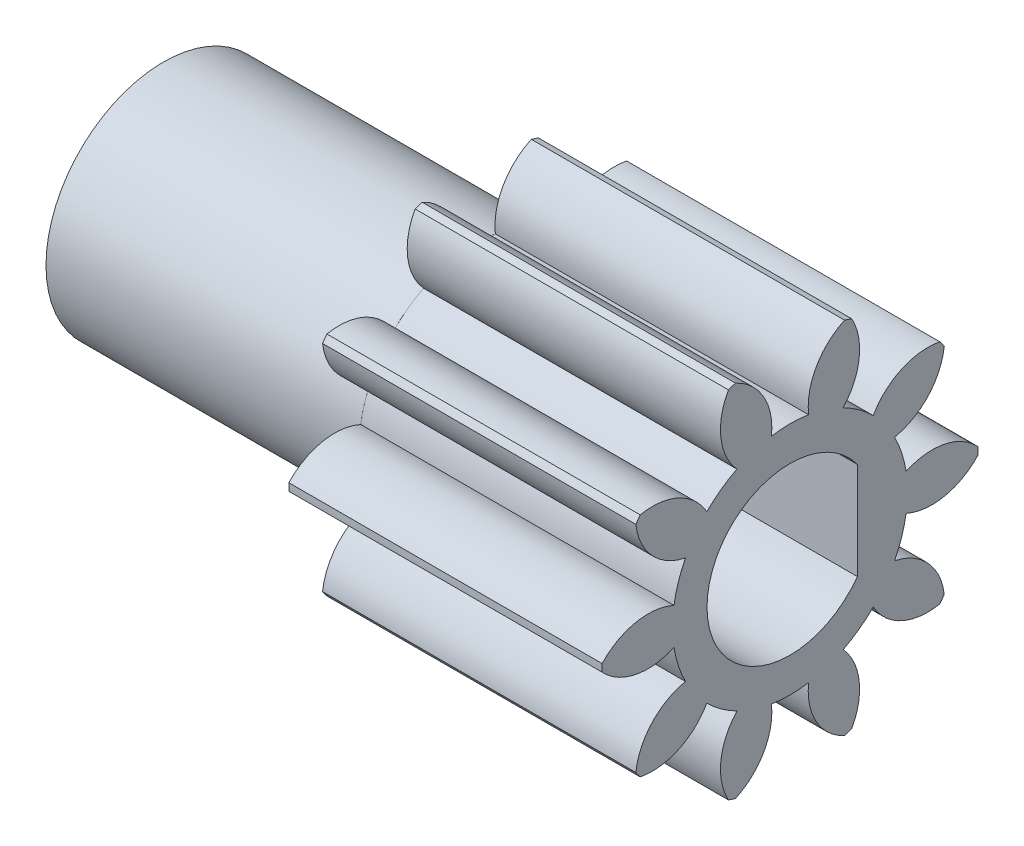
from build123d import *

# Parameters (mm, degrees)
BASPROSKE_W                  = 10
BASPROSKE_H                  = 6
TOOTHCUT_DEPTH               = 14.114877049
TEETHCUTS_COUNT              = 10
TEETHCUTS_ANGLE              = 324
BORSKE_R                     = 0.4
BORE_DEPTH                   = 50.0000508
CROQUIS1_R                   = 3.75
SALIENTE_EXTRUIR1_DEPTH      = 10
TALADRO_DE_MARGEN_PARA_M51_D = 5.3
SALIENTE_EXTRUIR2_DEPTH      = 10


with BuildPart() as part:
    # BasProSke → Base-Revolve (revolve)
    with BuildSketch(Plane(origin=(0, 0, 0), x_dir=(1, 0, 0), z_dir=(0, 1, 0)), mode=Mode.PRIVATE) as base_revolve_sk:
        with Locations((5, 3)):
            Rectangle(BASPROSKE_W, BASPROSKE_H)
    revolve(base_revolve_sk.sketch.rotate(Axis((-10, 0, 0), (1, 0, 0)), 180), axis=Axis((-10, 0, 0), (1, 0, 0)))

    # TooCutSke → ToothCut (cut, through all)
    with BuildSketch(Plane(origin=(0, 0, 0), x_dir=(0, 0, -1), z_dir=(1, 0, 0))):
        with BuildLine():
            ThreePointArc((0.59278292, 3.701838653), (0, 3.749), (-0.59278292, 3.701838653))
            ThreePointArc((-0.59278292, 3.701838653), (-0.846593509, 4.924114224), (-1.775771316, 5.757784417))
            ThreePointArc((-1.775771316, 5.757784417), (0, 6.0254), (1.775771316, 5.757784417))
            ThreePointArc((1.775771316, 5.757784417), (0.846593509, 4.924114224), (0.59278292, 3.701838653))
        make_face()
    toothcut = extrude(amount=TOOTHCUT_DEPTH, mode=Mode.SUBTRACT)

    # TeethCuts: ToothCut ×10 about axis
    teethcuts_axis = Axis((-10, 0, 0), (1, 0, 0))
    for i in range(1, TEETHCUTS_COUNT):
        add(toothcut.rotate(teethcuts_axis, i * TEETHCUTS_ANGLE / (TEETHCUTS_COUNT - 1)), mode=Mode.SUBTRACT)

    # BorSke → Bore (cut, symmetric)
    with BuildSketch(Plane(origin=(0, 0, 0), x_dir=(0, 0, -1), z_dir=(1, 0, 0))):
        with Locations(Location((0, 0, 0), (0, 0, 180))):
            Circle(BORSKE_R)
    extrude(amount=BORE_DEPTH, both=True, mode=Mode.SUBTRACT)

    # Croquis1 → Saliente-Extruir1 (add)
    with BuildSketch(Plane.ZY):
        with Locations(Location((0, 0, 0), (0, 0, 188.906595326))):
            Circle(CROQUIS1_R)
    extrude(amount=SALIENTE_EXTRUIR1_DEPTH)

    # Taladro de margen para M51 (through all)
    with Locations(Plane.ZY.offset(10)):
        with Locations((0, 0)):
            Hole(TALADRO_DE_MARGEN_PARA_M51_D / 2)

    # Croquis5 → Saliente-Extruir2 (add)
    with BuildSketch(Plane(origin=(10, 0, 0), x_dir=(0, 0, -1), z_dir=(1, 0, 0))):
        with BuildLine():
            Line((2.149418526, 0), (2.149418526, 1.55))
            ThreePointArc((2.149418526, 1.55), (2.65, 0), (2.149418526, -1.55))
            Line((2.149418526, -1.55), (2.149418526, 0))
        make_face()
    extrude(amount=-SALIENTE_EXTRUIR2_DEPTH)


solid = part.part
